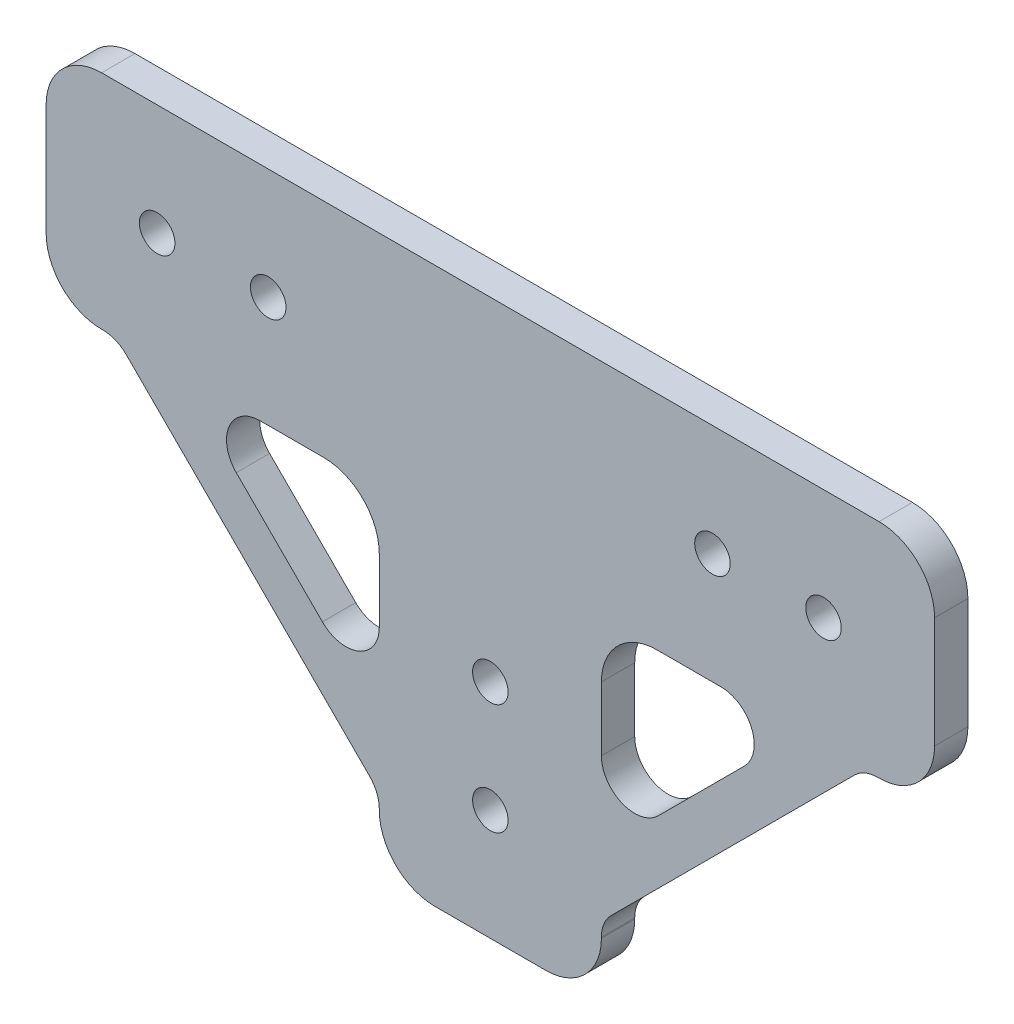
from build123d import *

# Parameters (mm, degrees)
SKETCH_1_R      = 1.6
EXTRUDE_1_DEPTH = 3
FILLET_1_R      = 5
EXTRUDE_2_DEPTH = 3
FILLET_2_R      = 3


with BuildPart() as part:
    # 草图1 → 凸台-拉伸1 (new body)
    with BuildSketch(Plane.XY):
        Polygon((-40, 0), (-40, 20), (40, 20), (40, 0), (10, 0), (10, -30), (-10, -30), (-10, 0), align=None)
        with Locations((-30, 10)):
            Circle(SKETCH_1_R, mode=Mode.SUBTRACT)
        with Locations((-20, 10)):
            Circle(SKETCH_1_R, mode=Mode.SUBTRACT)
        with Locations((0, -10)):
            Circle(SKETCH_1_R, mode=Mode.SUBTRACT)
        with Locations((0, -20)):
            Circle(SKETCH_1_R, mode=Mode.SUBTRACT)
        with Locations((20, 10)):
            Circle(SKETCH_1_R, mode=Mode.SUBTRACT)
        with Locations((30, 10)):
            Circle(SKETCH_1_R, mode=Mode.SUBTRACT)
    extrude(amount=EXTRUDE_1_DEPTH)

    # 圆角1
    fillet_1_edges = [part.edges().sort_by_distance(p)[0] for p in [
        (-40, 0, 1.5),
        (-40, 20, 1.5),
        (40, 20, 1.5),
        (40, 0, 1.5),
        (10, 0, 1.5),
        (10, -30, 1.5),
        (-10, -30, 1.5),
        (-10, 0, 1.5),
    ]]
    fillet(fillet_1_edges, radius=FILLET_1_R)

    # 草图2 → 凸台-拉伸2 (add)
    with BuildSketch(Plane(origin=(0, 0, 0), x_dir=(-1, 0, 0), z_dir=(0, 0, -1))):
        Polygon((-33.656854249, 0), (-10, -23.656854249), (-10, -18), (-28, 0), align=None)
        Polygon((10, -18), (28, 0), (33.656854249, 0), (10, -23.656854249), align=None)
    extrude(amount=-EXTRUDE_2_DEPTH)

    # 圆角2
    fillet_2_edges = [part.edges().sort_by_distance(p)[0] for p in [
        (33.656854249, 0, 1.5),
        (28, 0, 1.5),
        (10, -18, 1.5),
        (10, -23.656854249, 1.5),
        (-10, -23.656854249, 1.5),
        (-10, -18, 1.5),
        (-28, 0, 1.5),
        (-33.656854249, 0, 1.5),
    ]]
    fillet(fillet_2_edges, radius=FILLET_2_R)


solid = part.part
